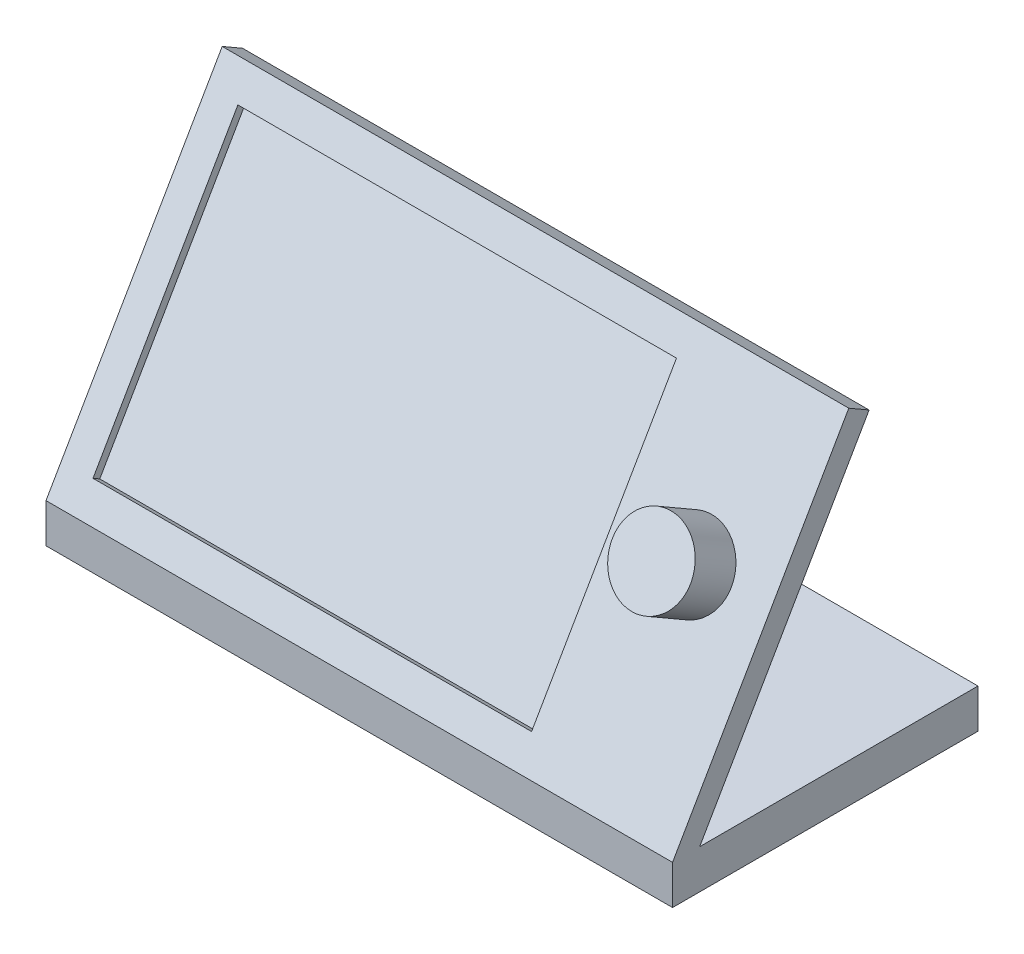
from build123d import *

# Parameters (mm, degrees)
SKETCH1_W                = 101.6
SKETCH1_H                = 6.35
BOSS_EXTRUDE1_DEPTH      = 25.4
BOSS_EXTRUDE1_DEPTH_BACK = 24.13
BOSS_EXTRUDE2_DEPTH      = 101.6
SKETCH3_W                = 71.12
SKETCH3_H                = 46.99
CUT_EXTRUDE1_DEPTH       = 1.27
SKETCH4_R                = 6.35
BOSS_EXTRUDE3_DEPTH      = 7.62


with BuildPart() as part:
    # Sketch1 → Boss-Extrude1 (new body, two sides)
    with BuildSketch(Plane.XY) as boss_extrude1_sk:
        with Locations((-50.8, 3.175)):
            Rectangle(SKETCH1_W, SKETCH1_H)
    extrude(amount=BOSS_EXTRUDE1_DEPTH)
    extrude(boss_extrude1_sk.sketch, amount=-BOSS_EXTRUDE1_DEPTH_BACK)

    # Sketch2 → Boss-Extrude2 (add)
    with BuildSketch(Plane(origin=(0, 0, 0), x_dir=(0, 0, -1), z_dir=(1, 0, 0))):
        Polygon((-25.4, 6.35), (3.175, 55.843351826), (6.474556788, 53.938351826), (-21.000590949, 6.35), align=None)
    extrude(amount=-BOSS_EXTRUDE2_DEPTH)

    # Sketch3 → Cut-Extrude1 (cut)
    with BuildSketch(Plane(origin=(0, 12.586022628, 21.799630657), x_dir=(1, 0, 0), z_dir=(0, 0.5, 0.866025404))):
        with Locations((-60.96, 21.374261314)):
            Rectangle(SKETCH3_W, SKETCH3_H)
    extrude(amount=-CUT_EXTRUDE1_DEPTH, mode=Mode.SUBTRACT)

    # Sketch4 → Boss-Extrude3 (add)
    with BuildSketch(Plane(origin=(0, 12.586022628, 21.799630657), x_dir=(1, 0, 0), z_dir=(0, 0.5, 0.866025404))):
        with Locations((-12.7, 24.549261314)):
            Circle(SKETCH4_R)
    extrude(amount=BOSS_EXTRUDE3_DEPTH)


solid = part.part
